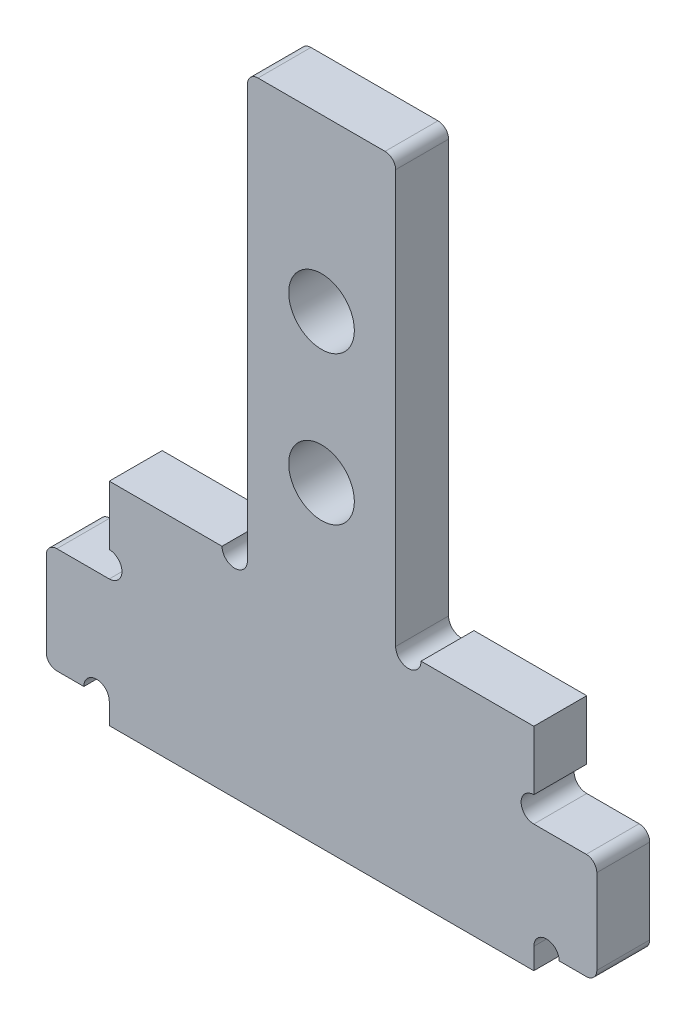
from build123d import *

# Parameters (mm, degrees)
EXTRUDE_1_DEPTH     = 1.25
SKETCH_2_R          = 0.6
CUT_EXTRUDE_1_DEPTH = 3.5
FILLET_1_R          = 0.5
SKETCH_3_R          = 1.55
CUT_EXTRUDE_2_DEPTH = 3.5


with BuildPart() as part:
    # 草图1 → 凸台-拉伸1 (new body, symmetric)
    with BuildSketch(Plane.XY):
        Polygon((-10.025, 6), (-13, 6), (-13, 1), (-10.025, 1), (-10.025, 0), (10.025, 0), (10.025, 1), (13, 1), (13, 6), (10.025, 6), (10.025, 10), (3.5, 10), (3.5, 30), (-3.5, 30), (-3.5, 10), (-10.025, 10), align=None)
    extrude(amount=EXTRUDE_1_DEPTH, both=True)

    # 草图2 → 切除-拉伸1 (cut, through all)
    with BuildSketch(Plane.XY.offset(1.25)):
        with Locations((-10.025, 6.6)):
            Circle(SKETCH_2_R)
        with Locations((-10.625, 1)):
            Circle(SKETCH_2_R)
        with Locations((10.025, 6.6)):
            Circle(SKETCH_2_R)
        with Locations((10.625, 1)):
            Circle(SKETCH_2_R)
        with Locations((-4.1, 10)):
            Circle(SKETCH_2_R)
        with Locations((4.1, 10)):
            Circle(SKETCH_2_R)
    extrude(amount=-CUT_EXTRUDE_1_DEPTH, mode=Mode.SUBTRACT)

    # 圆角1
    fillet_1_edges = [part.edges().sort_by_distance(p)[0] for p in [
        (-3.5, 30, 0),
        (3.5, 30, 0),
        (13, 6, 0),
        (13, 1, 0),
        (-13, 1, 0),
        (-13, 6, 0),
    ]]
    fillet(fillet_1_edges, radius=FILLET_1_R)

    # 草图3 → 切除-拉伸2 (cut, through all)
    with BuildSketch(Plane.XY.offset(1.25)):
        with Locations((0, 14.95)):
            Circle(SKETCH_3_R)
        with Locations((0, 21.95)):
            Circle(SKETCH_3_R)
    extrude(amount=-CUT_EXTRUDE_2_DEPTH, mode=Mode.SUBTRACT)


solid = part.part
